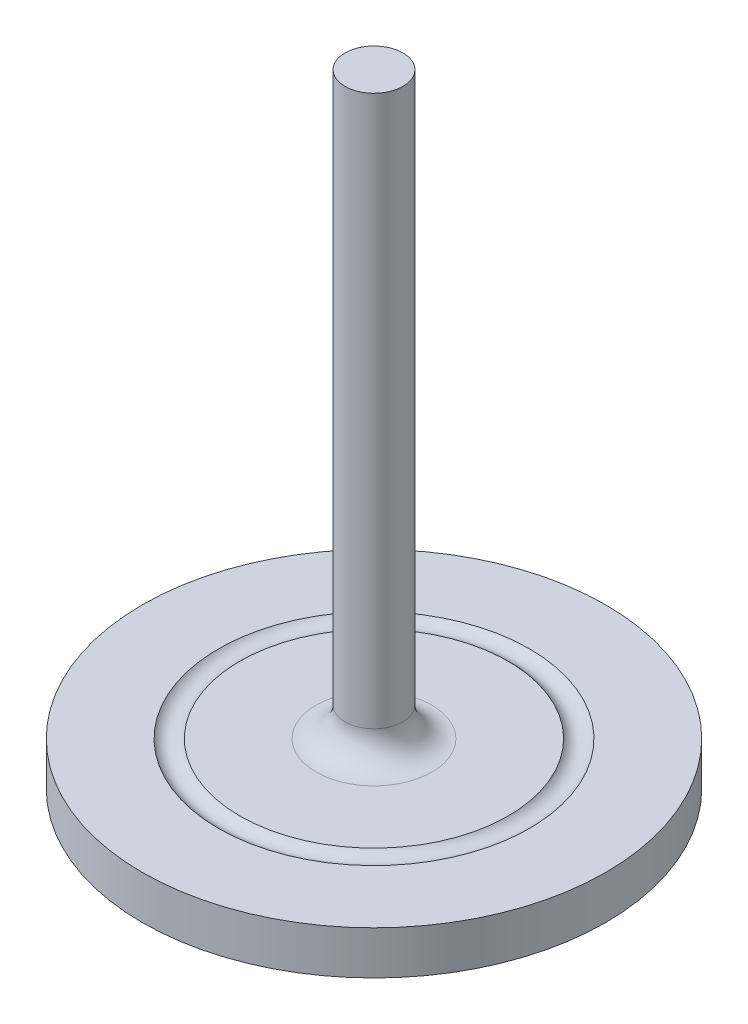
from build123d import *

# Parameters (mm, degrees)
SKETCH1_R            = 80
BOSS_EXTRUDE1_DEPTH  = 15
SKETCH16_R           = 10
BOSS_EXTRUDE2_DEPTH  = 200
FILLET1_R            = 10
CUT_SWEEP2_PROFILE_R = 4.7625


with BuildPart() as part:
    # Sketch1 → Boss-Extrude1 (new body)
    with BuildSketch(Plane(origin=(0, 0, 0), x_dir=(1, 0, 0), z_dir=(0, 1, 0))):
        Circle(SKETCH1_R)
    extrude(amount=BOSS_EXTRUDE1_DEPTH)

    # Sketch16 → Boss-Extrude2 (add)
    with BuildSketch(Plane(origin=(0, 15, 0), x_dir=(1, 0, 0), z_dir=(0, 1, 0))):
        Circle(SKETCH16_R)
    extrude(amount=BOSS_EXTRUDE2_DEPTH)

    # Fillet1
    fillet1_edges = [part.edges().sort_by_distance(p)[0] for p in [
        (-10, 15, 0),
    ]]
    fillet(fillet1_edges, radius=FILLET1_R)

    # Cut-Sweep2: sweep along a path in Sketch29
    with BuildLine(Plane(origin=(0, 18, 0), x_dir=(1, 0, 0), z_dir=(0, 1, 0))) as cut_sweep2_path:
        CenterArc((0, 0), 50, 0, 360)
    # Cut-Sweep2 profile (on start of the path) → Cut-Sweep2 (sweep, cut)
    with BuildSketch(Plane(origin=(50, 18, 0), x_dir=(-1, 0, 0), z_dir=(0, 0, -1))):
        Circle(CUT_SWEEP2_PROFILE_R)
    sweep(path=cut_sweep2_path.line, mode=Mode.SUBTRACT)


solid = part.part
